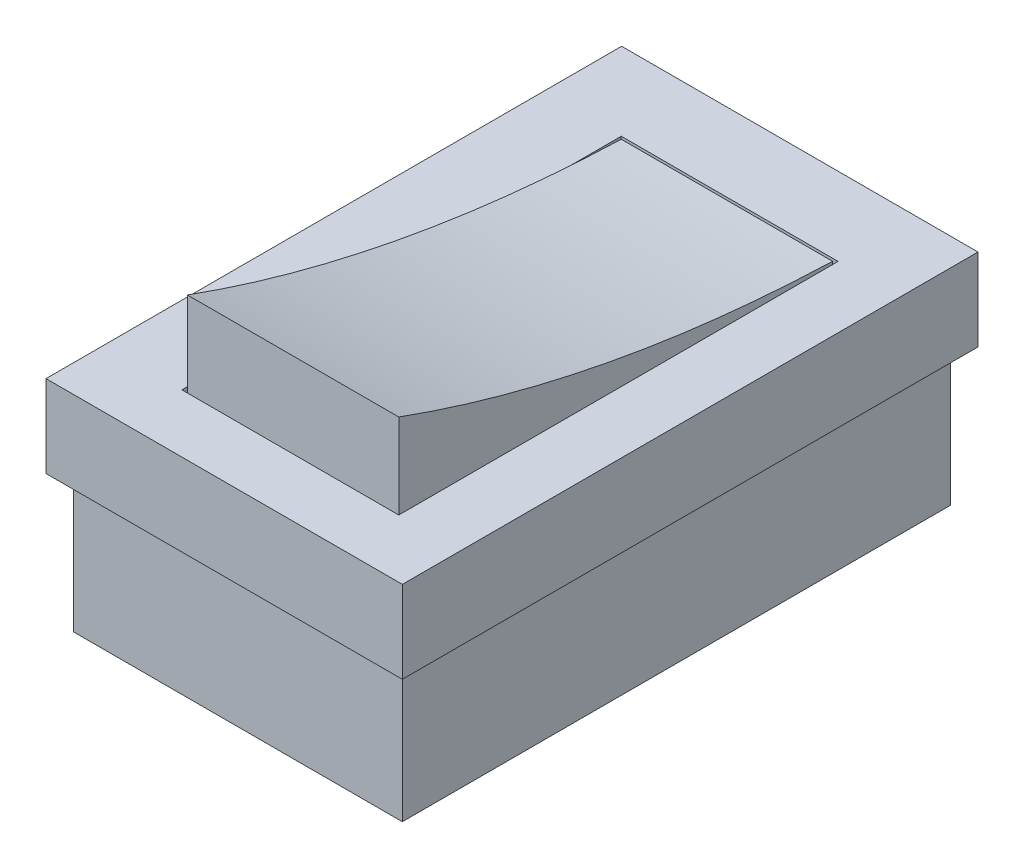
from build123d import *

# Parameters (mm, degrees)
SKETCH2_W                = 13
SKETCH2_H                = 21
SKETCH2_W_2              = 12
SKETCH2_H_2              = 20
BOSS_EXTRUDE1_DEPTH      = 3
BOSS_EXTRUDE2_DEPTH      = 3
BOSS_EXTRUDE2_DEPTH_BACK = 5
SKETCH2_2_W              = 12
SKETCH2_2_H              = 20
SKETCH3_W                = 7.910089125
SKETCH3_H                = 16.025972414
SKETCH3_W_2              = 7.710089125
SKETCH3_H_2              = 15.825972414
CUT_EXTRUDE1_DEPTH       = 3
SKETCH3_2_W              = 7.710089125
SKETCH3_2_H              = 15.825972414
BOSS_EXTRUDE3_DEPTH      = 3
CUT_EXTRUDE2_DEPTH       = 17.376015533


with BuildPart() as part:
    # Sketch2 → Boss-Extrude1 (new body)
    with BuildSketch(Plane(origin=(0, 0, 0), x_dir=(1, 0, 0), z_dir=(0, 1, 0))):
        with Locations((-0.268196817, 0.402295225)):
            Rectangle(SKETCH2_W, SKETCH2_H)
        with Locations((-0.268196817, 0.402295225)):
            Rectangle(SKETCH2_W_2, SKETCH2_H_2, mode=Mode.SUBTRACT)
    extrude(amount=BOSS_EXTRUDE1_DEPTH)

    # Sketch2_2 → Boss-Extrude2 (add, two sides: drawn at the far end of the back side and taken through both)
    with BuildSketch(Plane(origin=(0, 0, 0), x_dir=(1, 0, 0), z_dir=(0, 1, 0)).offset(-BOSS_EXTRUDE2_DEPTH_BACK)):
        with Locations((-0.268196817, 0.402295225)):
            Rectangle(SKETCH2_2_W, SKETCH2_2_H)
    extrude(amount=BOSS_EXTRUDE2_DEPTH + BOSS_EXTRUDE2_DEPTH_BACK)

    # Sketch3 → Cut-Extrude1 (cut)
    with BuildSketch(Plane(origin=(0, 3, 0), x_dir=(1, 0, 0), z_dir=(0, 1, 0))):
        with Locations((0.021656158, 0.039979007)):
            Rectangle(SKETCH3_W, SKETCH3_H)
        with Locations((0.021656157, 0.039979007)):
            Rectangle(SKETCH3_W_2, SKETCH3_H_2, mode=Mode.SUBTRACT)
    extrude(amount=-CUT_EXTRUDE1_DEPTH, mode=Mode.SUBTRACT)

    # Sketch3_2 → Boss-Extrude3 (add)
    with BuildSketch(Plane(origin=(0, 3, 0), x_dir=(1, 0, 0), z_dir=(0, 1, 0))):
        with Locations((0.021656157, 0.039979007)):
            Rectangle(SKETCH3_2_W, SKETCH3_2_H)
    extrude(amount=BOSS_EXTRUDE3_DEPTH)

    # Sketch5 → Cut-Extrude2 (cut, through all)
    with BuildSketch(Plane(origin=(3.87670072, 0, 0), x_dir=(0, 0, -1), z_dir=(1, 0, 0))):
        with BuildLine():
            add(Edge.make_bspline(
                [(7.952965214, 3.003696013), (-0.44948354, 3.292111909), (-7.8730072, 5.997516068)],
                knots=[0.001628514, 0.001628514, 0.001628514, 0.990717924, 0.990717924, 0.990717924], degree=2))
            Line((7.952965214, 3.003696013), (7.952965214, 6))
            Line((7.952965214, 6), (-7.8730072, 6))
            Line((-7.8730072, 6), (-7.8730072, 5.997516068))
        make_face()
    extrude(amount=-CUT_EXTRUDE2_DEPTH, mode=Mode.SUBTRACT)


solid = part.part
